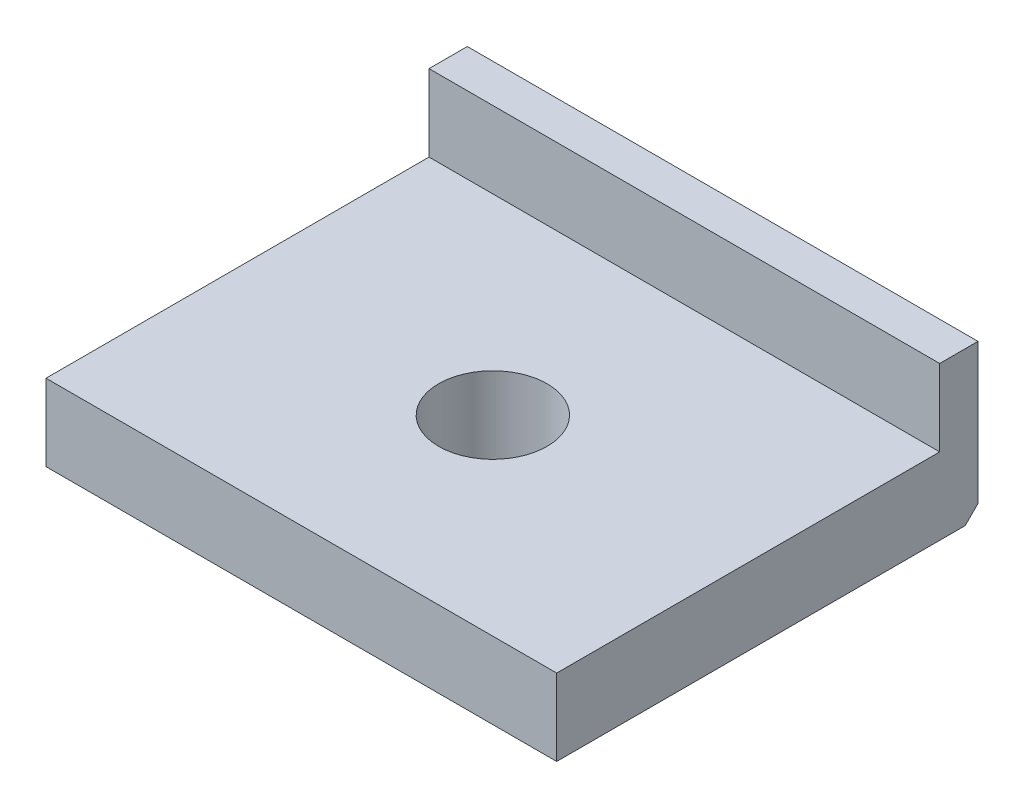
from build123d import *

# Parameters (mm, degrees)
SKETCH1_W               = 20
SKETCH1_H               = 18
BOSS_EXTRUDE1_DEPTH     = 6
SKETCH2_W               = 20
SKETCH2_H               = 3
BOSS_EXTRUDE2_DEPTH     = 3
SKETCH3_R               = 2.125
CUT_EXTRUDE1_DEPTH      = 1
CUT_EXTRUDE1_DEPTH_BACK = 10
CHAMFER1_SIZE           = 3
CHAMFER2_SIZE           = 5
CHAMFER3_SIZE           = 1.5


with BuildPart() as part:
    # Sketch1 → Boss-Extrude1 (new body)
    with BuildSketch(Plane(origin=(0, 0, 0), x_dir=(1, 0, 0), z_dir=(0, 1, 0))):
        Rectangle(SKETCH1_W, SKETCH1_H)
    extrude(amount=BOSS_EXTRUDE1_DEPTH)

    # Sketch2 → Boss-Extrude2 (add)
    with BuildSketch(Plane(origin=(0, 6, 0), x_dir=(1, 0, 0), z_dir=(0, 1, 0))):
        with Locations((0, 7.5)):
            Rectangle(SKETCH2_W, SKETCH2_H)
    extrude(amount=BOSS_EXTRUDE2_DEPTH)

    # Sketch3 → Cut-Extrude1 (cut, two sides)
    with BuildSketch(Plane.XZ) as cut_extrude1_sk:
        with Locations((0, 1.5)):
            Circle(SKETCH3_R)
    extrude(amount=CUT_EXTRUDE1_DEPTH, mode=Mode.SUBTRACT)
    extrude(cut_extrude1_sk.sketch, amount=-CUT_EXTRUDE1_DEPTH_BACK, mode=Mode.SUBTRACT)

    # Chamfer1
    chamfer1_edges = [part.edges().sort_by_distance(p)[0] for p in [
        (10, 0, 0),
        (0, 0, 9),
        (-10, 0, 0),
    ]]
    chamfer(chamfer1_edges, length=CHAMFER1_SIZE)

    # Chamfer2
    chamfer2_edges = [part.edges().sort_by_distance(p)[0] for p in [
        (0, 0, -9),
    ]]
    chamfer(chamfer2_edges, length=CHAMFER2_SIZE)

    # Chamfer3
    chamfer3_edges = [part.edges().sort_by_distance(p)[0] for p in [
        (0, 9, -9),
        (-10, 7, -9),
        (10, 7, -9),
    ]]
    chamfer(chamfer3_edges, length=CHAMFER3_SIZE)


solid = part.part
